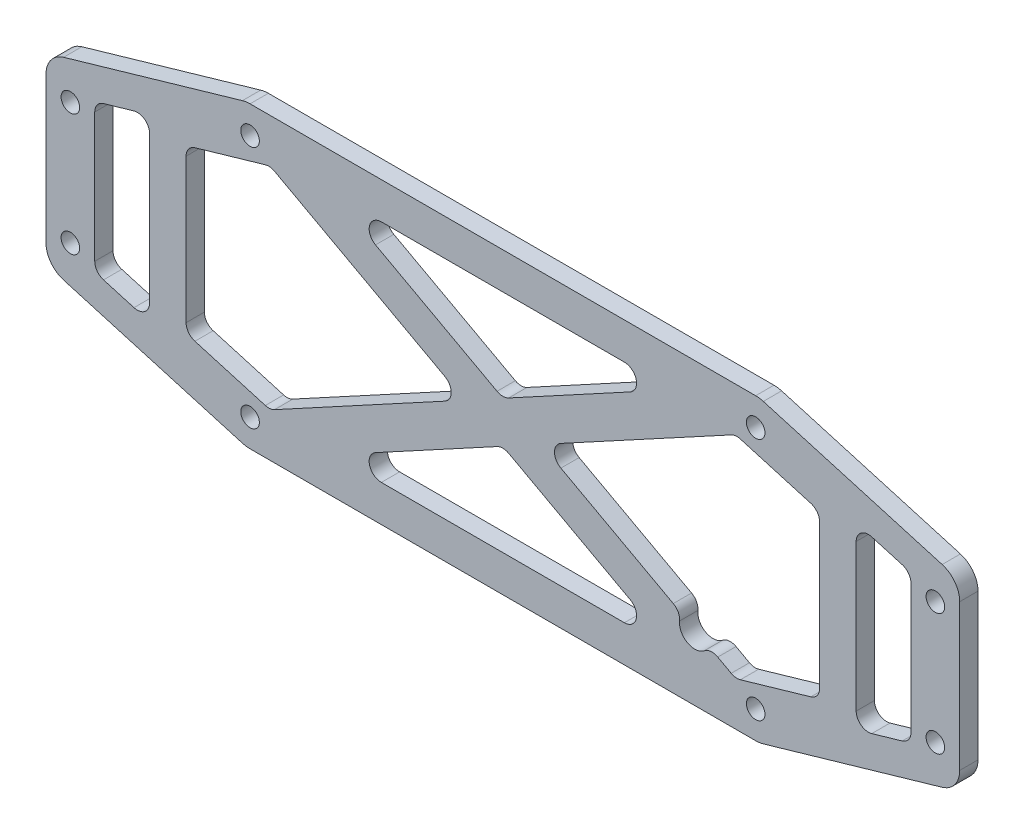
from build123d import *

# Parameters (mm, degrees)
SKETCH_1_R          = 1.525
EXTRUDE_1_DEPTH     = 3
FILLET_1_R          = 4
CUT_EXTRUDE_1_DEPTH = 10
FILLET_2_R          = 2
SKETCH_4_R          = 2.5
CUT_EXTRUDE_2_DEPTH = 10
FILLET_3_R          = 2


with BuildPart() as part:
    # 草图1 → 凸台-拉伸1 (new body)
    with BuildSketch(Plane.XY):
        with BuildLine():
            Line((75, -15), (75, 15))
            Line((75, 15), (42.759879905, 24.346070366))
            ThreePointArc((42.759879905, 24.346070366), (42.136261187, 24.480044275), (41.5, 24.525))
            Line((41.5, 24.525), (-41.5, 24.525))
            ThreePointArc((-41.5, 24.525), (-42.136261187, 24.480044275), (-42.759879905, 24.346070366))
            Line((-42.759879905, 24.346070366), (-75, 15))
            Line((-75, 15), (-75, -15))
            Line((-75, -15), (-42.759879905, -24.346070366))
            ThreePointArc((-42.759879905, -24.346070366), (-42.136261187, -24.480044275), (-41.5, -24.525))
            Line((-41.5, -24.525), (41.5, -24.525))
            ThreePointArc((41.5, -24.525), (42.136261187, -24.480044275), (42.759879905, -24.346070366))
            Line((42.759879905, -24.346070366), (75, -15))
        make_face()
        with Locations((-71, -10)):
            Circle(SKETCH_1_R, mode=Mode.SUBTRACT)
        with Locations((71, -10)):
            Circle(SKETCH_1_R, mode=Mode.SUBTRACT)
        with Locations((-71, 10)):
            Circle(SKETCH_1_R, mode=Mode.SUBTRACT)
        with Locations((71, 10)):
            Circle(SKETCH_1_R, mode=Mode.SUBTRACT)
        with Locations((-41.5, 20)):
            Circle(SKETCH_1_R, mode=Mode.SUBTRACT)
        with Locations((-41.5, -20)):
            Circle(SKETCH_1_R, mode=Mode.SUBTRACT)
        with Locations((41.5, 20)):
            Circle(SKETCH_1_R, mode=Mode.SUBTRACT)
        with Locations((41.5, -20)):
            Circle(SKETCH_1_R, mode=Mode.SUBTRACT)
    extrude(amount=EXTRUDE_1_DEPTH)

    # 圆角1
    fillet_1_edges = [part.edges().sort_by_distance(p)[0] for p in [
        (75, 15, 1.5),
        (75, -15, 1.5),
        (-75, -15, 1.5),
        (-75, 15, 1.5),
    ]]
    fillet(fillet_1_edges, radius=FILLET_1_R)

    # 草图2 → 切除-拉伸1 (cut)
    with BuildSketch(Plane.XY.offset(3)):
        Polygon((27.82171702, 18.525), (-27.82171702, 18.525), (0, 3.413941893), align=None)
        Polygon((-38.205524372, 17.336966413), (-52, 13.338093595), (-52, -13.338093595), (-38.205524372, -17.336966413), (-6.285577396, 0), align=None)
        Polygon((27.82171702, -18.525), (0, -3.413941893), (-27.82171702, -18.525), align=None)
        Polygon((38.205524372, 17.336966413), (6.285577396, 0), (38.205524372, -17.336966413), (52, -13.338093595), (52, 13.338093595), align=None)
        Polygon((58, -14.722268277), (58, 14.722268277), (67, 12.113263316), (67, -12.113263316), align=None)
        Polygon((-67, -12.113263316), (-58, -14.722268277), (-58, 14.722268277), (-67, 12.113263316), align=None)
    extrude(amount=-CUT_EXTRUDE_1_DEPTH, mode=Mode.SUBTRACT)

    # 圆角2
    fillet_2_edges = [part.edges().sort_by_distance(p)[0] for p in [
        (-58, -14.722268277, 1.5),
        (-67, -12.113263316, 1.5),
        (-67, 12.113263316, 1.5),
        (-58, 14.722268277, 1.5),
        (0, -3.413941893, 1.5),
        (27.82171702, -18.525, 1.5),
        (-27.82171702, -18.525, 1.5),
        (-6.285577396, 0, 1.5),
        (-38.205524372, -17.336966413, 1.5),
        (-52, -13.338093595, 1.5),
        (-52, 13.338093595, 1.5),
        (-38.205524372, 17.336966413, 1.5),
        (38.205524372, 17.336966413, 1.5),
        (52, 13.338093595, 1.5),
        (52, -13.338093595, 1.5),
        (38.205524372, -17.336966413, 1.5),
        (6.285577396, 0, 1.5),
        (58, -14.722268277, 1.5),
        (58, 14.722268277, 1.5),
        (67, 12.113263316, 1.5),
        (67, -12.113263316, 1.5),
        (-27.82171702, 18.525, 1.5),
        (27.82171702, 18.525, 1.5),
        (0, 3.413941893, 1.5),
    ]]
    fillet(fillet_2_edges, radius=FILLET_2_R)

    # 草图4 → 切除-拉伸2 (cut)
    with BuildSketch(Plane(origin=(0, 0, 0), x_dir=(-1, 0, 0), z_dir=(0, 0, -1))):
        with Locations((-31.5, -14)):
            Circle(SKETCH_4_R)
    extrude(amount=-CUT_EXTRUDE_2_DEPTH, mode=Mode.SUBTRACT)

    # 圆角3
    fillet_3_edges = [part.edges().sort_by_distance(p)[0] for p in [
        (33.812155271, -14.950756542, 1.5),
        (29.443740814, -12.57810051, 1.5),
    ]]
    fillet(fillet_3_edges, radius=FILLET_3_R)


solid = part.part
